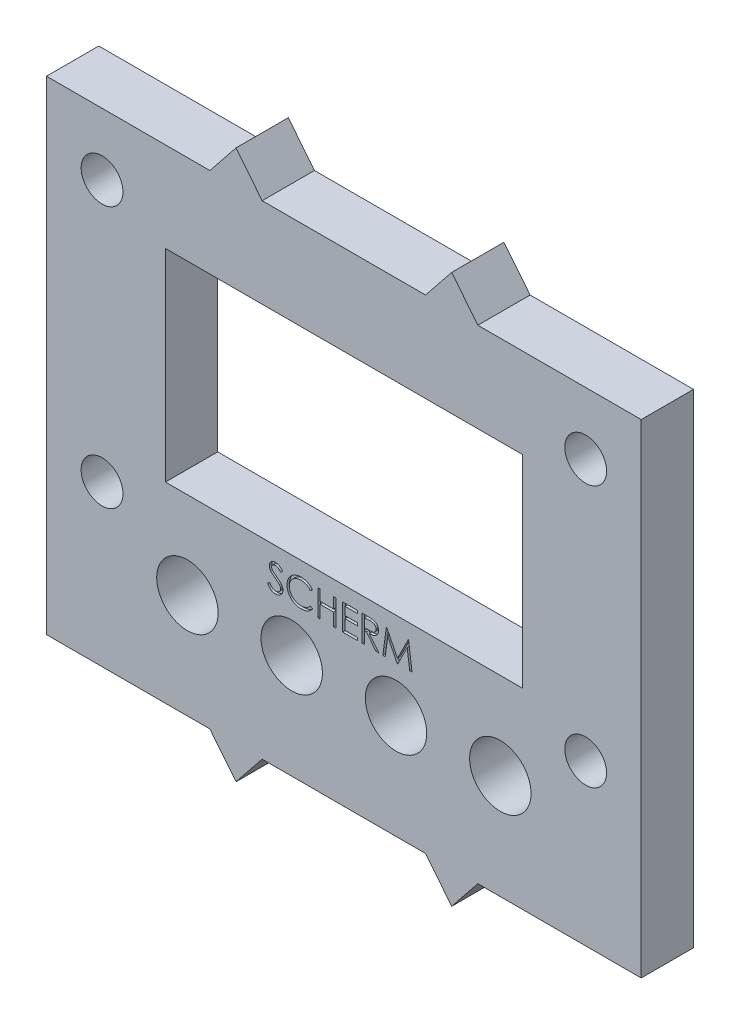
from build123d import *

# Parameters (mm, degrees)
SKETCH1_W              = 45.5
SKETCH1_H              = 37
BASIS_DEPTH            = 4
SKETCH6_W              = 27.3
SKETCH6_H              = 15.480915405
SHOW_ONLY_SCREEN_DEPTH = 10.04
SKETCH11_R             = 1.6
CUT_EXTRUDE10_DEPTH    = 4
SKETCH12_R             = 2.35
LEGO_GATEN_DEPTH       = 10
CUT_EXTRUDE11_DEPTH    = 0.2


with BuildPart() as part:
    # Sketch1 → Basis (new body)
    with BuildSketch(Plane.XY):
        with Locations((22.75, 18.5)):
            Rectangle(SKETCH1_W, SKETCH1_H)
        Polygon((14.5, 39.5), (12.5, 37), (16.5, 37), align=None)
        Polygon((31, 39.5), (29, 37), (33, 37), align=None)
        Polygon((16.5, 0), (12.5, 0), (14.5, -2.5), align=None)
        Polygon((33, 0), (29, 0), (31, -2.5), align=None)
    extrude(amount=BASIS_DEPTH)

    # Sketch6 → Show only screen (cut)
    with BuildSketch(Plane.XY.offset(4)):
        with Locations((22.75, 22.399542298)):
            Rectangle(SKETCH6_W, SKETCH6_H)
    extrude(amount=-SHOW_ONLY_SCREEN_DEPTH, mode=Mode.SUBTRACT)

    # Sketch11 → Cut-Extrude10 (cut)
    with BuildSketch(Plane(origin=(0, 0, 0), x_dir=(-1, 0, 0), z_dir=(0, 0, -1))):
        with Locations((-41.25, 32.252592082)):
            Circle(SKETCH11_R)
        with Locations((-4.25, 32.252592082)):
            Circle(SKETCH11_R)
        with Locations((-4.25, 12.252592082)):
            Circle(SKETCH11_R)
        with Locations((-41.25, 12.252592082)):
            Circle(SKETCH11_R)
    extrude(amount=-CUT_EXTRUDE10_DEPTH, mode=Mode.SUBTRACT)

    # Sketch12 → Lego gaten (cut)
    with BuildSketch(Plane(origin=(0, 0, 0), x_dir=(-1, 0, 0), z_dir=(0, 0, -1))):
        with Locations((-34.72, 8)):
            Circle(SKETCH12_R)
        with Locations((-18.76, 8)):
            Circle(SKETCH12_R)
        with Locations((-26.74, 8)):
            Circle(SKETCH12_R)
        with Locations((-10.78, 8)):
            Circle(SKETCH12_R)
    extrude(amount=-LEGO_GATEN_DEPTH, mode=Mode.SUBTRACT)

    # Sketch9 → Cut-Extrude11 (cut)
    with BuildSketch(Plane.XY.offset(4)):
        with BuildLine():
            Line((16.91543911, 11.885817308), (17.084509623, 11.987179487))
            add(Edge.make_bspline(
                [(17.084509623, 11.987179487), (17.10023433, 11.960856981), (17.130362261, 11.910424076), (17.180620181, 11.842276625), (17.23269613, 11.784355392), (17.286975749, 11.736997331), (17.34312772, 11.699712253), (17.401518608, 11.673310977), (17.461951642, 11.656844706), (17.50307954, 11.654844656), (17.523612187, 11.653846154)],
                knots=[0, 0, 0, 0, 9.1943e-05, 0.00017616, 0.000253587, 0.00032516, 0.000391722, 0.000455019, 0.000516726, 0.000578245, 0.000578245, 0.000578245, 0.000578245], degree=3))
            add(Edge.make_bspline(
                [(17.523612187, 11.653846154), (17.541147536, 11.654334538), (17.575911406, 11.655302761), (17.62708983, 11.664606077), (17.676793717, 11.678898722), (17.723998653, 11.699367825), (17.76805329, 11.724132674), (17.806685688, 11.754044776), (17.840083466, 11.787534036), (17.867402961, 11.824895553), (17.888362981, 11.865076781), (17.904472734, 11.906320182), (17.913412776, 11.949273649), (17.914759492, 11.978193914), (17.91543911, 11.992788462)],
                knots=[0, 0, 0, 0, 5.2559e-05, 0.000104198, 0.000155544, 0.000207414, 0.000258201, 0.000306763, 0.000353508, 0.000399665, 0.000445008, 0.000489133, 0.000532114, 0.000575902, 0.000575902, 0.000575902, 0.000575902], degree=3))
            add(Edge.make_bspline(
                [(17.91543911, 11.992788462), (17.914596647, 12.009440376), (17.912884042, 12.043291284), (17.89840891, 12.093233943), (17.875637912, 12.142658268), (17.854630687, 12.17323042), (17.843724366, 12.189102564)],
                knots=[0, 0, 0, 0, 4.9875e-05, 0.000101388, 0.000154805, 0.000212482, 0.000212482, 0.000212482, 0.000212482], degree=3))
            add(Edge.make_bspline(
                [(17.843724366, 12.189102564), (17.83476973, 12.200557892), (17.81597059, 12.22460692), (17.783652011, 12.260404197), (17.745728517, 12.297329008), (17.703497915, 12.336791326), (17.655421864, 12.376955781), (17.603006141, 12.419737654), (17.544912508, 12.463509984), (17.504169938, 12.492865736), (17.483147443, 12.508012821)],
                knots=[0, 0, 0, 0, 4.3611e-05, 9.1556e-05, 0.000144533, 0.00020237, 0.000264903, 0.000332417, 0.000405335, 0.000483068, 0.000483068, 0.000483068, 0.000483068], degree=3))
            add(Edge.make_bspline(
                [(17.483147443, 12.508012821), (17.46210516, 12.523000585), (17.421873916, 12.551656049), (17.365611869, 12.594184211), (17.315300747, 12.633066422), (17.271164166, 12.668668715), (17.233221539, 12.700995918), (17.201173876, 12.729737597), (17.175837558, 12.755671061), (17.161748654, 12.772494685), (17.155423084, 12.780048077)],
                knots=[0, 0, 0, 0, 7.7499e-05, 0.000148172, 0.000211562, 0.000268251, 0.000318269, 0.000361092, 0.000397358, 0.000426908, 0.000426908, 0.000426908, 0.000426908], degree=3))
            add(Edge.make_bspline(
                [(17.155423084, 12.780048077), (17.14658163, 12.791820098), (17.129193723, 12.814971357), (17.10624172, 12.85115699), (17.086733627, 12.888198856), (17.071440866, 12.926196493), (17.058563026, 12.964616452), (17.049901352, 13.003960021), (17.044477696, 13.044050661), (17.043922275, 13.071029804), (17.043644238, 13.084535256)],
                knots=[0, 0, 0, 0, 4.4154e-05, 8.6835e-05, 0.000128409, 0.000169553, 0.000209589, 0.000249829, 0.00029023, 0.000330726, 0.000330726, 0.000330726, 0.000330726], degree=3))
            add(Edge.make_bspline(
                [(17.043644238, 13.084535256), (17.044390072, 13.105695128), (17.045865797, 13.147562593), (17.058346093, 13.208723067), (17.078044889, 13.267115306), (17.105641968, 13.322161211), (17.141217598, 13.372427485), (17.182386727, 13.418492335), (17.231421862, 13.457217239), (17.285223361, 13.491052701), (17.344112716, 13.517536087), (17.405821804, 13.53751379), (17.470448702, 13.548833366), (17.514221922, 13.550457803), (17.5364327, 13.551282051)],
                knots=[0, 0, 0, 0, 6.3428e-05, 0.0001255, 0.000186441, 0.000247897, 0.000309471, 0.000370729, 0.000432548, 0.00049625, 0.000560973, 0.00062572, 0.000690402, 0.000757029, 0.000757029, 0.000757029, 0.000757029], degree=3))
            add(Edge.make_bspline(
                [(17.5364327, 13.551282051), (17.560000757, 13.550469165), (17.606870101, 13.548852593), (17.67581251, 13.53479686), (17.742190062, 13.511539334), (17.795586213, 13.485145815), (17.837376363, 13.458785006), (17.869246496, 13.434773678), (17.901542182, 13.407130758), (17.934523927, 13.375782618), (17.967632876, 13.340441617), (18.001360563, 13.301349795), (18.035785859, 13.258746049), (18.057932065, 13.228332048), (18.069285264, 13.212740385)],
                knots=[0, 0, 0, 0, 7.065e-05, 0.000140501, 0.000210062, 0.000281193, 0.00031865, 0.000358154, 0.000400784, 0.000446125, 0.00049459, 0.000545998, 0.000600997, 0.000658851, 0.000658851, 0.000658851, 0.000658851], degree=3))
            Line((18.069285264, 13.212740385), (17.907025648, 13.08974359))
            add(Edge.make_bspline(
                [(17.907025648, 13.08974359), (17.897227973, 13.102365699), (17.87835994, 13.126672929), (17.849714519, 13.160713681), (17.822715292, 13.191808812), (17.796115063, 13.218817456), (17.771318702, 13.243218676), (17.747251821, 13.264109965), (17.724260763, 13.28169602), (17.695279671, 13.300463768), (17.658869547, 13.319067485), (17.613164097, 13.334809815), (17.565400512, 13.34426985), (17.532869294, 13.345520643), (17.516400648, 13.346153846)],
                knots=[0, 0, 0, 0, 4.793e-05, 9.2302e-05, 0.000133459, 0.000171424, 0.000205991, 0.000237801, 0.000266968, 0.00029275, 0.000341307, 0.0003892, 0.000437365, 0.000486748, 0.000486748, 0.000486748, 0.000486748], degree=3))
            add(Edge.make_bspline(
                [(17.516400648, 13.346153846), (17.495739778, 13.345461446), (17.455897237, 13.344126218), (17.399331388, 13.329543369), (17.348420573, 13.306582306), (17.304676251, 13.274402319), (17.268255121, 13.236276037), (17.241909144, 13.192402406), (17.226051907, 13.143955319), (17.224116891, 13.110160086), (17.223131417, 13.092948718)],
                knots=[0, 0, 0, 0, 6.1856e-05, 0.000119283, 0.00017396, 0.000228453, 0.000281174, 0.000331125, 0.000380792, 0.000432338, 0.000432338, 0.000432338, 0.000432338], degree=3))
            add(Edge.make_bspline(
                [(17.223131417, 13.092948718), (17.223356061, 13.082233587), (17.223805716, 13.060785805), (17.230077029, 13.029099278), (17.238133789, 12.997492798), (17.250901007, 12.966108465), (17.268526895, 12.934397403), (17.291672709, 12.901813553), (17.320823173, 12.868069719), (17.343152895, 12.846122649), (17.354942315, 12.834535256)],
                knots=[0, 0, 0, 0, 3.2091e-05, 6.4235e-05, 9.6598e-05, 0.000129854, 0.000165538, 0.000205219, 0.000249544, 0.000299122, 0.000299122, 0.000299122, 0.000299122], degree=3))
            add(Edge.make_bspline(
                [(17.354942315, 12.834535256), (17.359320242, 12.830628385), (17.369721195, 12.821346551), (17.388736009, 12.806150962), (17.41384618, 12.787406521), (17.444396009, 12.764213769), (17.480948787, 12.737310076), (17.523508534, 12.707039441), (17.571600838, 12.672419178), (17.605727647, 12.648214869), (17.623772443, 12.635416667)],
                knots=[0, 0, 0, 0, 1.7601e-05, 4.1816e-05, 7.2986e-05, 0.000111608, 0.000156882, 0.000209138, 0.000268286, 0.000334654, 0.000334654, 0.000334654, 0.000334654], degree=3))
            add(Edge.make_bspline(
                [(17.623772443, 12.635416667), (17.645478679, 12.619621604), (17.687509797, 12.589036654), (17.747314129, 12.543084837), (17.801539162, 12.498143255), (17.850375278, 12.454498908), (17.89430494, 12.412482855), (17.93284078, 12.371589609), (17.966375455, 12.332112139), (18.002477866, 12.281499239), (18.039368048, 12.219338619), (18.07104891, 12.143179626), (18.091025108, 12.066724586), (18.093637403, 12.015337822), (18.094926289, 11.989983974)],
                knots=[0, 0, 0, 0, 8.0533e-05, 0.000155941, 0.000226217, 0.000291762, 0.000352398, 0.000408517, 0.000460275, 0.000507641, 0.000594907, 0.000676453, 0.00075448, 0.000830472, 0.000830472, 0.000830472, 0.000830472], degree=3))
            add(Edge.make_bspline(
                [(18.094926289, 11.989983974), (18.094550782, 11.97205348), (18.093807059, 11.936540689), (18.085257965, 11.884394931), (18.072732442, 11.83374872), (18.053854023, 11.785228084), (18.030812218, 11.737945363), (18.001574362, 11.693140848), (17.967684257, 11.649822906), (17.92880782, 11.609146625), (17.886267304, 11.571805942), (17.841305193, 11.538589335), (17.793847894, 11.510893151), (17.744152856, 11.488292669), (17.692208663, 11.470616374), (17.638032787, 11.45780902), (17.581535923, 11.449948614), (17.543135648, 11.44913275), (17.523612187, 11.448717949)],
                knots=[0, 0, 0, 0, 5.374e-05, 0.000106436, 0.000158131, 0.000209993, 0.000262312, 0.000315656, 0.000370156, 0.000427116, 0.000484178, 0.000539791, 0.000594555, 0.000648701, 0.000703308, 0.000758893, 0.000815497, 0.00087404, 0.00087404, 0.00087404, 0.00087404], degree=3))
            add(Edge.make_bspline(
                [(17.523612187, 11.448717949), (17.508506276, 11.449010052), (17.478484699, 11.449590581), (17.434079281, 11.454722742), (17.390570944, 11.461983944), (17.34850564, 11.473511984), (17.307341405, 11.487498828), (17.267257271, 11.504720732), (17.228233812, 11.525359133), (17.190052336, 11.54895629), (17.15280995, 11.576417858), (17.116855969, 11.608402713), (17.08101072, 11.644028716), (17.046332208, 11.684263324), (17.012118982, 11.728456514), (16.979045605, 11.777021761), (16.946427481, 11.829694535), (16.925961499, 11.866760298), (16.91543911, 11.885817308)],
                knots=[0, 0, 0, 0, 4.5301e-05, 9.0031e-05, 0.000133965, 0.000177502, 0.000220706, 0.000264317, 0.000308224, 0.000353028, 0.000398862, 0.00044684, 0.000497267, 0.000550371, 0.000606066, 0.000664853, 0.000726559, 0.000791857, 0.000791857, 0.000791857, 0.000791857], degree=3))
        make_face()
        with BuildLine():
            Line((20.351336546, 13.133012821), (20.194285264, 13.012820513))
            add(Edge.make_bspline(
                [(20.194285264, 13.012820513), (20.183081899, 13.026172496), (20.160826215, 13.052696447), (20.125020956, 13.089941901), (20.087705732, 13.124836337), (20.048894805, 13.157545982), (20.007889594, 13.186926991), (19.965683424, 13.214510478), (19.921570255, 13.2392349), (19.860569264, 13.269213749), (19.780770493, 13.300497266), (19.6803163, 13.326727684), (19.575452815, 13.343425499), (19.503911329, 13.34523398), (19.467522443, 13.346153846)],
                knots=[0, 0, 0, 0, 5.2277e-05, 0.000103849, 0.000154871, 0.000205501, 0.000255988, 0.000306107, 0.000356696, 0.000407582, 0.000509955, 0.00061316, 0.000718552, 0.000827651, 0.000827651, 0.000827651, 0.000827651], degree=3))
            add(Edge.make_bspline(
                [(19.467522443, 13.346153846), (19.447474844, 13.34592301), (19.407565705, 13.345463481), (19.348338006, 13.339401124), (19.290216262, 13.330880433), (19.233238282, 13.318237391), (19.177476591, 13.302253037), (19.122566647, 13.283152801), (19.069303447, 13.259521463), (19.016950168, 13.233402458), (18.966790619, 13.203901061), (18.919330592, 13.171722003), (18.874743181, 13.137225376), (18.832993117, 13.100281887), (18.794037718, 13.061057909), (18.758159255, 13.019135428), (18.725481878, 12.974648472), (18.695357863, 12.928183668), (18.668379159, 12.879876358), (18.645790656, 12.829547747), (18.625787729, 12.778059688), (18.60995959, 12.724830453), (18.597431295, 12.670234587), (18.588786916, 12.614125565), (18.582793504, 12.556620605), (18.58233626, 12.517643855), (18.582105776, 12.497996795)],
                knots=[0, 0, 0, 0, 6.0118e-05, 0.000119677, 0.000178435, 0.000236274, 0.000294609, 0.00035239, 0.000410522, 0.00046929, 0.000527833, 0.00058495, 0.000641206, 0.000696836, 0.00075208, 0.000806921, 0.000862211, 0.000917553, 0.000972966, 0.001028007, 0.001082918, 0.001138561, 0.001194446, 0.001250828, 0.001308793, 0.001367709, 0.001367709, 0.001367709, 0.001367709], degree=3))
            add(Edge.make_bspline(
                [(18.582105776, 12.497996795), (18.582826816, 12.468436041), (18.584242481, 12.410397421), (18.596841529, 12.325385643), (18.615987296, 12.243945258), (18.644681911, 12.166585348), (18.680064226, 12.092352001), (18.724773147, 12.022501228), (18.776554025, 11.955977476), (18.836139408, 11.894352935), (18.90151416, 11.838059377), (18.971655823, 11.788487617), (19.046389702, 11.747164827), (19.124890634, 11.712778571), (19.207762699, 11.686346156), (19.294856872, 11.667738085), (19.385983726, 11.655599696), (19.448251954, 11.654437589), (19.479942315, 11.653846154)],
                knots=[0, 0, 0, 0, 8.8632e-05, 0.000174018, 0.000257294, 0.00033917, 0.000421059, 0.000503533, 0.000587444, 0.000673582, 0.000760233, 0.000845931, 0.000930763, 0.001015987, 0.001102652, 0.001191215, 0.0012829, 0.00137792, 0.00137792, 0.00137792, 0.00137792], degree=3))
            add(Edge.make_bspline(
                [(19.479942315, 11.653846154), (19.514858137, 11.654811171), (19.583580828, 11.656710555), (19.684362557, 11.672801555), (19.780840138, 11.698891793), (19.873018759, 11.735404892), (19.960638556, 11.782870771), (20.043836648, 11.840412415), (20.12268326, 11.908577176), (20.170095421, 11.960624678), (20.194285264, 11.987179487)],
                knots=[0, 0, 0, 0, 0.000104697, 0.000206069, 0.0003053, 0.000404025, 0.000502796, 0.000603594, 0.000706976, 0.000814666, 0.000814666, 0.000814666, 0.000814666], degree=3))
            Line((20.194285264, 11.987179487), (20.351336546, 11.868189103))
            add(Edge.make_bspline(
                [(20.351336546, 11.868189103), (20.338697626, 11.851881416), (20.313480326, 11.819344155), (20.272647173, 11.773474607), (20.229631575, 11.730329443), (20.184114026, 11.690256517), (20.136618145, 11.652453965), (20.086291109, 11.617995776), (20.033794519, 11.586400985), (19.979306246, 11.557471314), (19.922884181, 11.531804316), (19.864595933, 11.509830734), (19.804692747, 11.490902226), (19.743171885, 11.47532969), (19.679905738, 11.463174785), (19.61512261, 11.455049257), (19.548682681, 11.449482449), (19.503859012, 11.448975068), (19.481144238, 11.448717949)],
                knots=[0, 0, 0, 0, 6.1882e-05, 0.000123467, 0.000184093, 0.000244547, 0.000305303, 0.000366091, 0.00042738, 0.000489032, 0.000551069, 0.000613201, 0.000675796, 0.000739442, 0.000803481, 0.000868928, 0.000935239, 0.001003366, 0.001003366, 0.001003366, 0.001003366], degree=3))
            add(Edge.make_bspline(
                [(19.481144238, 11.448717949), (19.459633571, 11.448867659), (19.417098891, 11.449163692), (19.354299604, 11.453959216), (19.293162701, 11.460501923), (19.233862915, 11.470353426), (19.176076643, 11.481978763), (19.120327738, 11.497562339), (19.066067618, 11.515019005), (19.01351428, 11.535536141), (18.962623023, 11.558688245), (18.913557988, 11.58485485), (18.866341741, 11.613815916), (18.820510072, 11.644933064), (18.776740024, 11.679205808), (18.734652295, 11.716158171), (18.69401088, 11.755665606), (18.668866489, 11.784154093), (18.656224366, 11.798477564)],
                knots=[0, 0, 0, 0, 6.4514e-05, 0.000127569, 0.000188846, 0.000248916, 0.000307847, 0.000365579, 0.000422466, 0.000478787, 0.000534724, 0.000590106, 0.000645488, 0.000700828, 0.000756207, 0.000812138, 0.0008688, 0.000926095, 0.000926095, 0.000926095, 0.000926095], degree=3))
            add(Edge.make_bspline(
                [(18.656224366, 11.798477564), (18.635975427, 11.823358243), (18.595722012, 11.872819221), (18.544221621, 11.952982639), (18.500137304, 12.036678758), (18.464493921, 12.124347289), (18.436629502, 12.21579151), (18.417325962, 12.311057518), (18.404782188, 12.410056342), (18.403347737, 12.47739165), (18.402618597, 12.51161859)],
                knots=[0, 0, 0, 0, 9.6175e-05, 0.000191188, 0.000285271, 0.000379609, 0.000474663, 0.000571623, 0.000670911, 0.000773553, 0.000773553, 0.000773553, 0.000773553], degree=3))
            add(Edge.make_bspline(
                [(18.402618597, 12.51161859), (18.403507279, 12.547593135), (18.405255705, 12.618370806), (18.420110446, 12.722241636), (18.444006901, 12.821756721), (18.47794798, 12.91673029), (18.520979609, 13.007661878), (18.574137674, 13.093856853), (18.636804613, 13.175866452), (18.708488937, 13.25244631), (18.787098843, 13.322468797), (18.871281022, 13.384072342), (18.960870706, 13.435339494), (19.054880907, 13.478194444), (19.154015582, 13.511134138), (19.258063222, 13.534193101), (19.366828316, 13.548545739), (19.441035416, 13.550360144), (19.478740392, 13.551282051)],
                knots=[0, 0, 0, 0, 0.00010788, 0.000212246, 0.000314083, 0.000414445, 0.000514263, 0.00061534, 0.000717667, 0.000823401, 0.000929537, 0.001033073, 0.001135741, 0.001238661, 0.00134255, 0.001448495, 0.001557971, 0.001671054, 0.001671054, 0.001671054, 0.001671054], degree=3))
            add(Edge.make_bspline(
                [(19.478740392, 13.551282051), (19.50172009, 13.551006544), (19.547206089, 13.550461204), (19.614493319, 13.545143409), (19.68000322, 13.536278491), (19.743780924, 13.524212165), (19.806136704, 13.509236553), (19.866593985, 13.489727811), (19.92550752, 13.467421222), (19.982505753, 13.44173067), (20.037315211, 13.412892532), (20.089918821, 13.381226461), (20.13989874, 13.346771715), (20.187606654, 13.309821329), (20.232244489, 13.269593581), (20.275079619, 13.227194955), (20.314657378, 13.181404198), (20.339087775, 13.149172808), (20.351336546, 13.133012821)],
                knots=[0, 0, 0, 0, 6.8929e-05, 0.000136438, 0.000202334, 0.00026716, 0.000331099, 0.000394578, 0.000457601, 0.000520004, 0.00058201, 0.000643299, 0.000704087, 0.000764033, 0.000824188, 0.000884247, 0.000944738, 0.001005563, 0.001005563, 0.001005563, 0.001005563], degree=3))
        make_face()
        Polygon((20.761592956, 13.5), (20.941080135, 13.5), (20.941080135, 12.679487179), (21.966721161, 12.679487179), (21.966721161, 13.5), (22.146208341, 13.5), (22.146208341, 11.5), (21.966721161, 11.5), (21.966721161, 12.474358974), (20.941080135, 12.474358974), (20.941080135, 11.5), (20.761592956, 11.5), align=None)
        Polygon((22.659028853, 13.5), (23.787233982, 13.5), (23.787233982, 13.294871795), (22.838516033, 13.294871795), (22.838516033, 12.679487179), (23.787233982, 12.679487179), (23.787233982, 12.474358974), (22.838516033, 12.474358974), (22.838516033, 11.705128205), (23.787233982, 11.705128205), (23.787233982, 11.5), (22.659028853, 11.5), align=None)
        with BuildLine():
            Line((24.146208341, 13.5), (24.546448725, 13.5))
            add(Edge.make_bspline(
                [(24.546448725, 13.5), (24.573157941, 13.499911094), (24.624442595, 13.499740384), (24.697913036, 13.498788519), (24.764671377, 13.496060316), (24.824682714, 13.493712554), (24.877945945, 13.489431445), (24.924624397, 13.485339646), (24.964503081, 13.479983269), (24.988643568, 13.475008741), (24.999573725, 13.47275641)],
                knots=[0, 0, 0, 0, 8.0129e-05, 0.000153857, 0.000220407, 0.000280568, 0.000334004, 0.000380687, 0.000421142, 0.000454614, 0.000454614, 0.000454614, 0.000454614], degree=3))
            add(Edge.make_bspline(
                [(24.999573725, 13.47275641), (25.014206082, 13.469141116), (25.043158647, 13.461987651), (25.084844399, 13.446867879), (25.12456687, 13.429370951), (25.162161055, 13.408820253), (25.19743865, 13.385063236), (25.230763399, 13.358510023), (25.262286521, 13.329305906), (25.290733167, 13.296714568), (25.317555482, 13.262522277), (25.340177555, 13.225548701), (25.3596784, 13.186884971), (25.37520441, 13.146137875), (25.387706109, 13.103702577), (25.396521103, 13.059194693), (25.401807496, 13.012816993), (25.402345699, 12.981183903), (25.402618597, 12.965144231)],
                knots=[0, 0, 0, 0, 4.5189e-05, 8.9414e-05, 0.000132818, 0.000175313, 0.00021776, 0.000260245, 0.000303046, 0.000346465, 0.000389898, 0.000433258, 0.000476259, 0.000519636, 0.000563882, 0.000608826, 0.000655591, 0.000703695, 0.000703695, 0.000703695, 0.000703695], degree=3))
            add(Edge.make_bspline(
                [(25.402618597, 12.965144231), (25.401779169, 12.9384956), (25.400141229, 12.886497218), (25.384869741, 12.811033857), (25.359854587, 12.740639963), (25.325384136, 12.67540417), (25.281487293, 12.616598087), (25.228730269, 12.564946398), (25.167083634, 12.521723591), (25.109695454, 12.49175056), (25.059001625, 12.472554612), (25.017268304, 12.459048121), (24.971744317, 12.448612712), (24.92286584, 12.439264066), (24.870429465, 12.432205955), (24.814560871, 12.427036472), (24.755220213, 12.423805587), (24.714455031, 12.423324441), (24.693483982, 12.423076923)],
                knots=[0, 0, 0, 0, 7.9872e-05, 0.000155852, 0.000229857, 0.000303339, 0.000376336, 0.000449148, 0.000523852, 0.000601441, 0.00064266, 0.000686374, 0.000732921, 0.00078266, 0.000835638, 0.00089157, 0.000950951, 0.001013863, 0.001013863, 0.001013863, 0.001013863], degree=3))
            Line((24.693483982, 12.423076923), (25.428259623, 11.5))
            Line((25.428259623, 11.5), (25.206304494, 11.5))
            Line((25.206304494, 11.5), (24.471528853, 12.423076923))
            Line((24.471528853, 12.423076923), (24.32569552, 12.423076923))
            Line((24.32569552, 12.423076923), (24.32569552, 11.5))
            Line((24.32569552, 11.5), (24.146208341, 11.5))
            Line((24.146208341, 11.5), (24.146208341, 13.5))
        make_face()
        with BuildLine():
            Line((24.32569552, 13.294871795), (24.32569552, 12.628205128))
            Line((24.32569552, 12.628205128), (24.691881417, 12.625400641))
            add(Edge.make_bspline(
                [(24.691881417, 12.625400641), (24.708978583, 12.625393077), (24.742117758, 12.625378416), (24.790060995, 12.627660574), (24.834701059, 12.630256756), (24.875867203, 12.634227811), (24.913577818, 12.639345566), (24.947814054, 12.645747271), (24.978631798, 12.653205593), (25.01457382, 12.664749379), (25.05470898, 12.683038532), (25.098326957, 12.709647389), (25.13547115, 12.743115457), (25.166852786, 12.781386003), (25.192069604, 12.82346386), (25.209847921, 12.868844642), (25.221129316, 12.916382698), (25.222459914, 12.949055902), (25.223131417, 12.965544872)],
                knots=[0, 0, 0, 0, 5.1284e-05, 9.9402e-05, 0.000143962, 0.000185422, 0.000223441, 0.000258093, 0.000289868, 0.000318502, 0.000371222, 0.000421801, 0.000471176, 0.000520422, 0.000569825, 0.000617663, 0.00066616, 0.000715571, 0.000715571, 0.000715571, 0.000715571], degree=3))
            add(Edge.make_bspline(
                [(25.223131417, 12.965544872), (25.222444491, 12.981628628), (25.221083254, 13.013500765), (25.209969672, 13.060161285), (25.19117574, 13.104199542), (25.165848747, 13.145436391), (25.134992087, 13.18286824), (25.098810479, 13.214895184), (25.058293225, 13.24132345), (25.020423969, 13.258211667), (24.986575847, 13.268565869), (24.95718747, 13.275852248), (24.923980911, 13.281706231), (24.886794935, 13.286396551), (24.845788289, 13.290427948), (24.800753631, 13.29314325), (24.751989757, 13.294751172), (24.71819151, 13.294830652), (24.70069552, 13.294871795)],
                knots=[0, 0, 0, 0, 4.8212e-05, 9.5538e-05, 0.000142938, 0.000191311, 0.000240248, 0.000287926, 0.00033571, 0.00038485, 0.000411714, 0.000441837, 0.000475629, 0.0005128, 0.00055426, 0.00059922, 0.000648124, 0.00070061, 0.00070061, 0.00070061, 0.00070061], degree=3))
            Line((24.70069552, 13.294871795), (24.32569552, 13.294871795))
        make_face(mode=Mode.SUBTRACT)
        Polygon((25.73595193, 11.5), (25.999974366, 13.5), (26.025615392, 13.5), (26.851336546, 11.858974359), (27.675054494, 13.5), (27.701096161, 13.5), (27.966721161, 11.5), (27.7864327, 11.5), (27.594926289, 12.939102564), (26.872971161, 11.5), (26.832506417, 11.5), (26.107746802, 12.942307692), (25.916641033, 11.5), align=None)
    extrude(amount=-CUT_EXTRUDE11_DEPTH, mode=Mode.SUBTRACT)


solid = part.part
